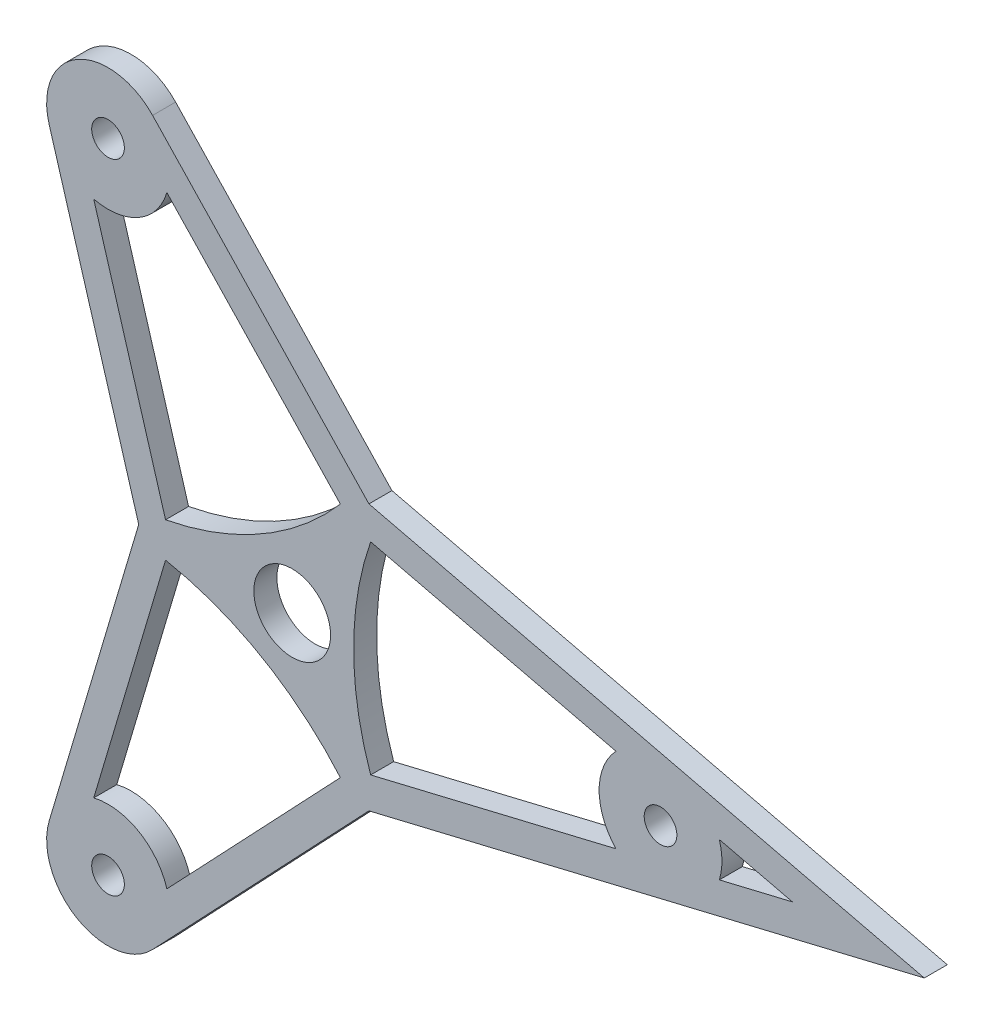
from build123d import *

# Parameters (mm, degrees)
SKETCH1_R                = 7.9375
BOSS_EXTRUDE1_DEPTH      = 4.7625
H_0_266_DIAMETER_HOLE1_D = 6.7564


with BuildPart() as part:
    # Sketch1 → Boss-Extrude1 (new body)
    with BuildSketch(Plane.XY):
        with BuildLine():
            Line((-31.75, 0), (-50.274457233, 62.375531935))
            ThreePointArc((-50.274457233, 62.375531935), (-44.45, 76.989658396), (-28.881566614, 74.726723093))
            Line((-28.881566614, 74.726723093), (15.875, 27.49630657))
            Line((15.875, 27.49630657), (78.9111987, 12.409785423))
            Line((78.9111987, 12.409785423), (130.763159277, 0))
            Line((130.763159277, 0), (79.156023847, -12.351191158))
            Line((79.156023847, -12.351191158), (15.875, -27.49630657))
            Line((15.875, -27.49630657), (-28.881566614, -74.726723093))
            ThreePointArc((-28.881566614, -74.726723093), (-44.45, -76.989658396), (-50.274457233, -62.375531935))
            Line((-50.274457233, -62.375531935), (-31.75, 0))
        make_face()
        Circle(SKETCH1_R, mode=Mode.SUBTRACT)
        with BuildLine():
            Line((9.968214912, 24.497802386), (-25.925542767, 62.375531935))
            ThreePointArc((-25.925542767, 62.375531935), (-31.75, 54.99261314), (-41.056023847, 53.639944611))
            Line((-41.056023847, 53.639944611), (-26.199826659, 3.616173849))
            ThreePointArc((-26.199826659, 3.616173849), (-6.35, 10.998522628), (9.968214912, 24.497802386))
        make_face(mode=Mode.SUBTRACT)
        with BuildLine():
            Line((16.231611747, 20.881628537), (66.981566614, 8.735587325))
            ThreePointArc((66.981566614, 8.735587325), (63.5, 0), (66.981566614, -8.735587325))
            Line((66.981566614, -8.735587325), (16.231611747, -20.881628537))
            ThreePointArc((16.231611747, -20.881628537), (12.7, 0), (16.231611747, 20.881628537))
        make_face(mode=Mode.SUBTRACT)
        with BuildLine():
            Line((88.374457233, 3.615603833), (103.481579639, 0))
            Line((103.481579639, 0), (88.374457233, -3.615603833))
            ThreePointArc((88.374457233, -3.615603833), (88.9, 0), (88.374457233, 3.615603833))
        make_face(mode=Mode.SUBTRACT)
        with BuildLine():
            Line((9.968214912, -24.497802386), (-25.925542767, -62.375531935))
            ThreePointArc((-25.925542767, -62.375531935), (-31.75, -54.99261314), (-41.056023847, -53.639944611))
            Line((-41.056023847, -53.639944611), (-26.199826659, -3.616173849))
            ThreePointArc((-26.199826659, -3.616173849), (-6.35, -10.998522628), (9.968214912, -24.497802386))
        make_face(mode=Mode.SUBTRACT)
    extrude(amount=-BOSS_EXTRUDE1_DEPTH)

    # H (0.266) Diameter Hole1 (through all)
    with Locations(Plane.XY):
        with Locations((76.2, 0), (-38.1, 65.991135768), (-38.1, -65.991135768)):
            Hole(H_0_266_DIAMETER_HOLE1_D / 2)


solid = part.part
